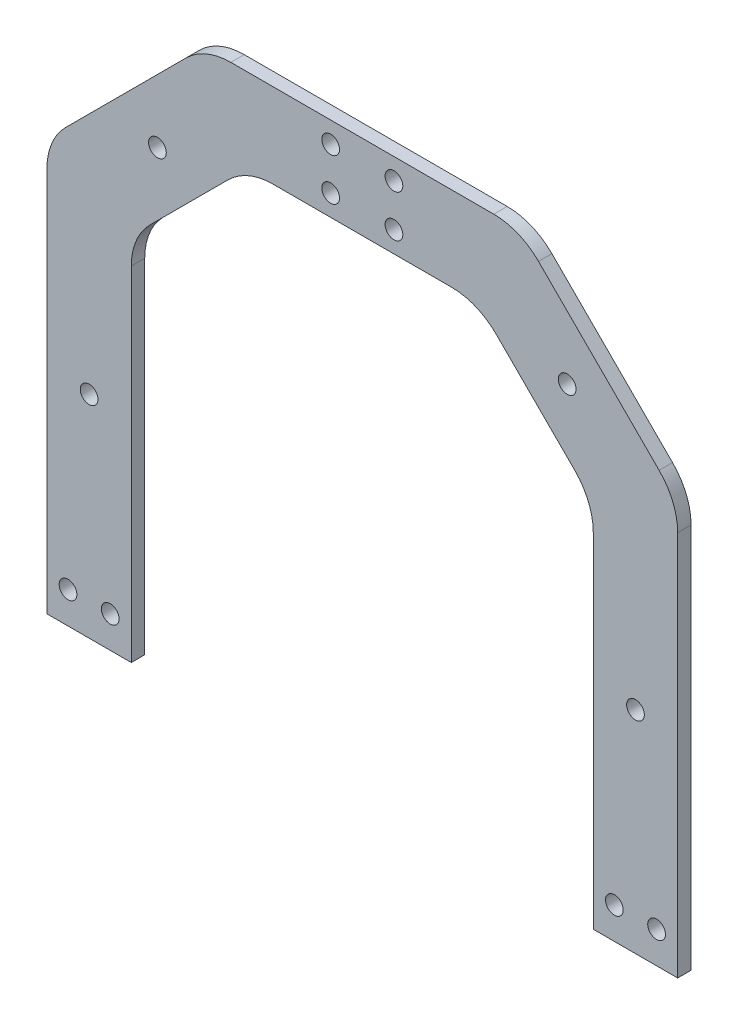
from build123d import *

# Parameters (mm, degrees)
SALIENTE_EXTRUIR1_DEPTH      = 6.35
TALADRO_DE_MARGEN_PARA_M81_D = 8.4


with BuildPart() as part:
    # Croquis1 → Saliente-Extruir1 (new body)
    with BuildSketch(Plane.XY):
        with BuildLine():
            Line((-63.536796564, 221.213203436), (-100.713203436, 184.036796564))
            ThreePointArc((-100.713203436, 184.036796564), (-107.216385975, 174.3040961), (-109.5, 162.823593129))
            Line((-109.5, 162.823593129), (-109.5, 0))
            Line((-109.5, 0), (-149.5, 0))
            Line((-149.5, 0), (-149.5, 182.823593129))
            ThreePointArc((-149.5, 182.823593129), (-147.216385975, 194.3040961), (-140.713203436, 204.036796564))
            Line((-140.713203436, 204.036796564), (-83.536796564, 261.213203436))
            ThreePointArc((-83.536796564, 261.213203436), (-73.8040961, 267.716385975), (-62.323593129, 270))
            Line((-62.323593129, 270), (62.323593129, 270))
            ThreePointArc((62.323593129, 270), (73.8040961, 267.716385975), (83.536796564, 261.213203436))
            Line((83.536796564, 261.213203436), (140.713203436, 204.036796564))
            ThreePointArc((140.713203436, 204.036796564), (147.216385975, 194.3040961), (149.5, 182.823593129))
            Line((149.5, 182.823593129), (149.5, 0))
            Line((149.5, 0), (109.5, 0))
            Line((109.5, 0), (109.5, 162.823593129))
            ThreePointArc((109.5, 162.823593129), (107.216385975, 174.3040961), (100.713203436, 184.036796564))
            Line((100.713203436, 184.036796564), (63.536796564, 221.213203436))
            ThreePointArc((63.536796564, 221.213203436), (53.8040961, 227.716385975), (42.323593129, 230))
            Line((42.323593129, 230), (-42.323593129, 230))
            ThreePointArc((-42.323593129, 230), (-53.8040961, 227.716385975), (-63.536796564, 221.213203436))
        make_face()
    extrude(amount=SALIENTE_EXTRUIR1_DEPTH)

    # Taladro de margen para M81 (through all)
    with Locations(Plane.XY.offset(6.35)):
        with Locations((-119.5, 15), (-139.5, 15), (0, 15), (139.5, 15), (-15, 260), (-15, 240), (15, 240), (15, 260), (-129.5, 100.125), (-97.125, 217.625), (129.5, 100.125), (97.125, 217.625), (119.5, 15)):
            Hole(TALADRO_DE_MARGEN_PARA_M81_D / 2)


solid = part.part
